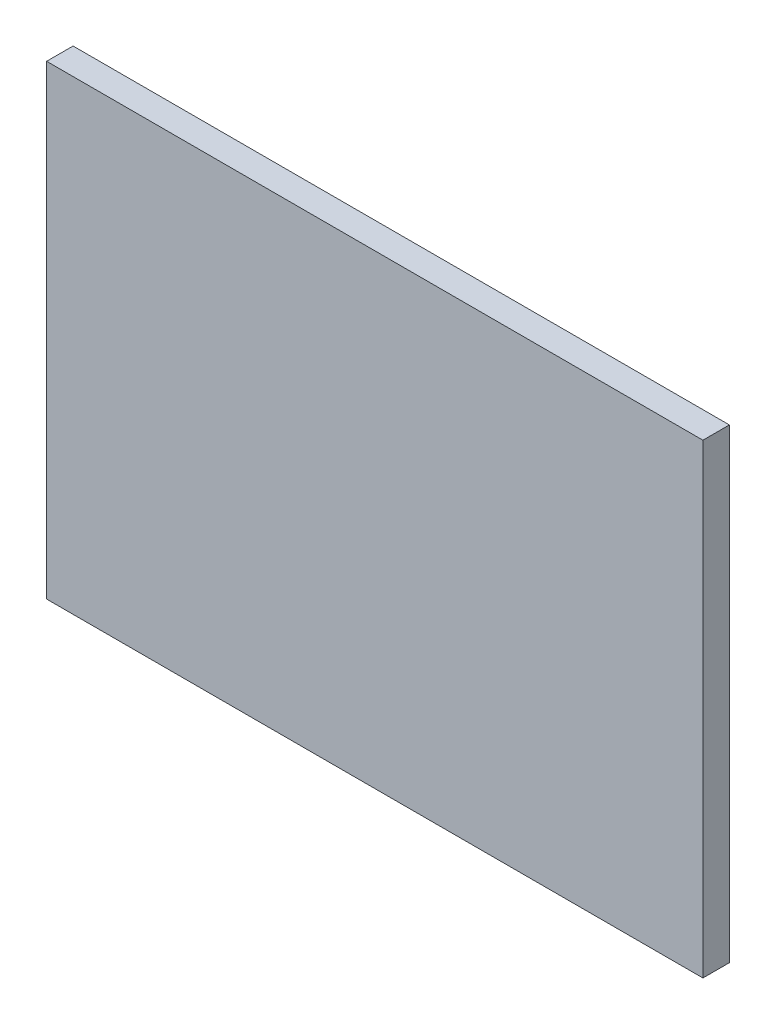
from build123d import *

# Parameters (mm, degrees)
SKETCH1_W           = 787.4
SKETCH1_H           = 558.8
BOSS_EXTRUDE1_DEPTH = 31.75


with BuildPart() as part:
    # Sketch1 → Boss-Extrude1 (new body)
    with BuildSketch(Plane.XY):
        with Locations((393.7, 279.4)):
            Rectangle(SKETCH1_W, SKETCH1_H)
    extrude(amount=BOSS_EXTRUDE1_DEPTH)


solid = part.part
